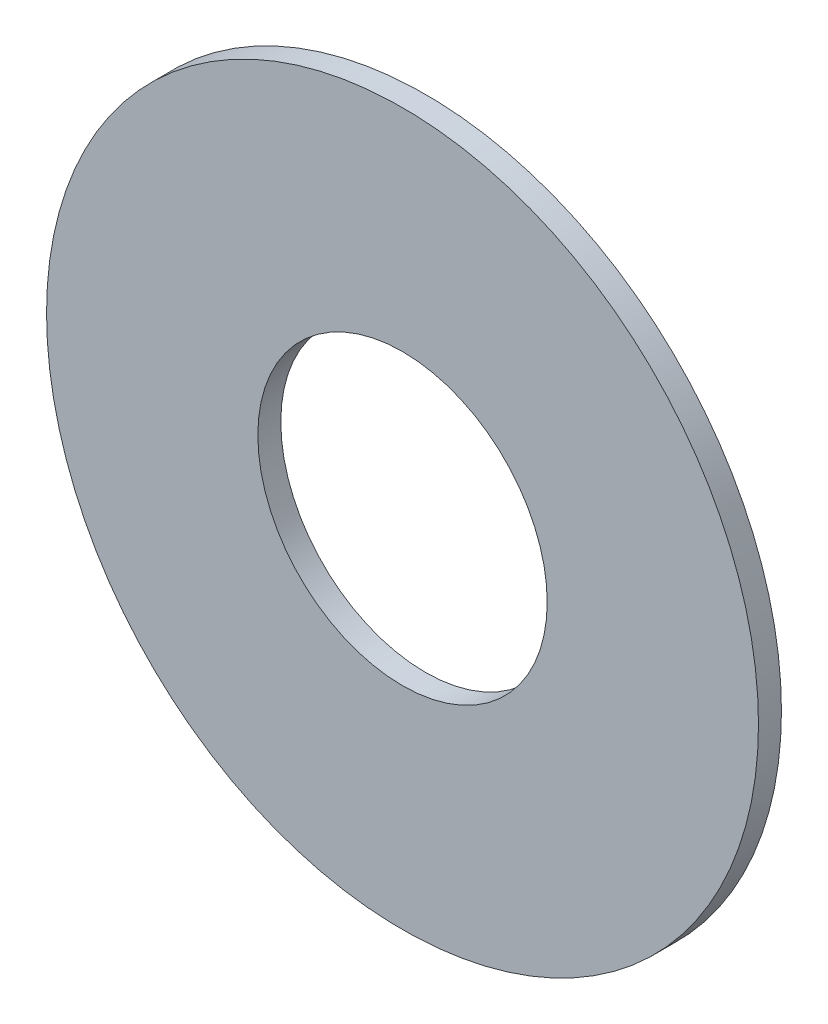
from build123d import *

# Parameters (mm, degrees)
SKETCH1_R           = 3.937
SKETCH1_R_2         = 1.6002
BOSS_EXTRUDE1_DEPTH = 0.254


with BuildPart() as part:
    # Sketch1 → Boss-Extrude1 (new body)
    with BuildSketch(Plane.XY):
        Circle(SKETCH1_R)
        Circle(SKETCH1_R_2, mode=Mode.SUBTRACT)
    extrude(amount=BOSS_EXTRUDE1_DEPTH)


solid = part.part
